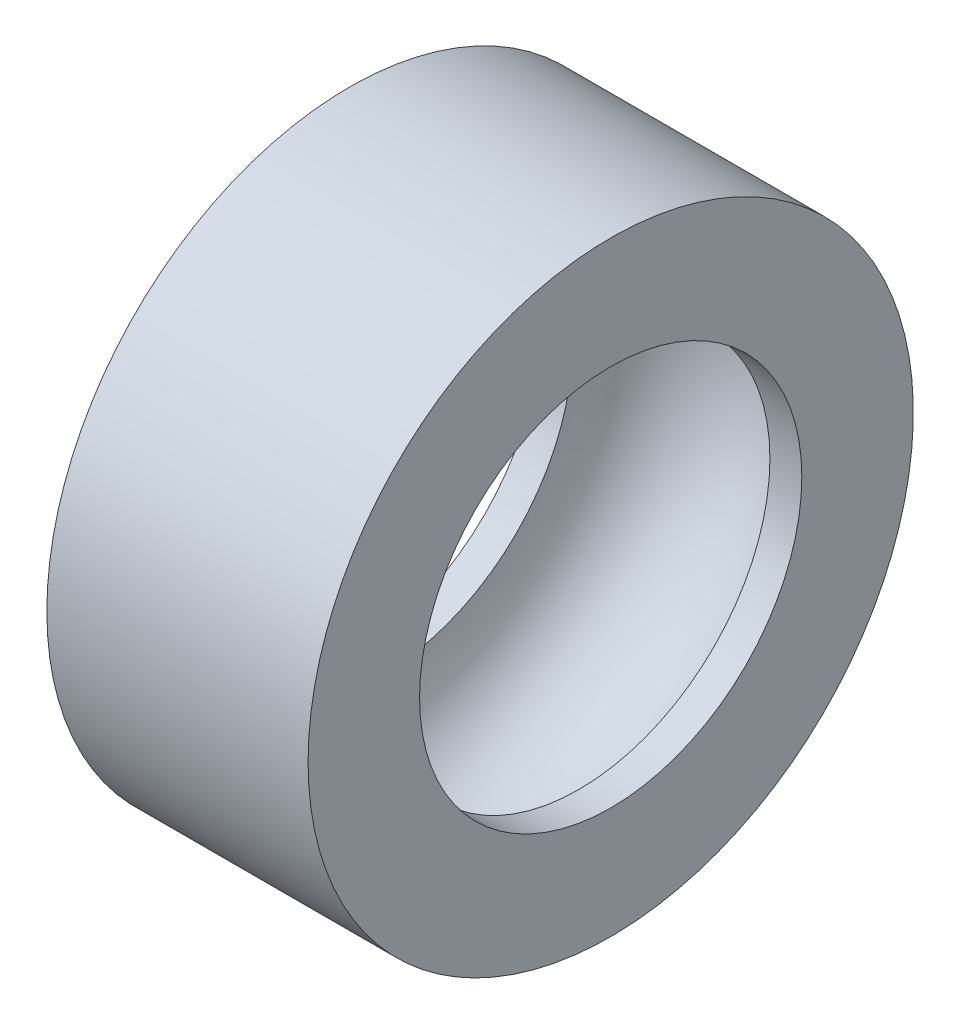
from build123d import *


with BuildPart() as part:
    # Sketch1 → Revolve1 (revolve)
    with BuildSketch(Plane.XY):
        with BuildLine():
            Line((4.1, 6), (3.098386677, 6))
            ThreePointArc((3.098386677, 6), (0, 9), (-3.098386677, 6))
            Line((-3.098386677, 6), (-4.1, 6))
            Line((-4.1, 6), (-4.1, 9.5))
            Line((-4.1, 9.5), (4.1, 9.5))
            Line((4.1, 9.5), (4.1, 6))
        make_face()
    revolve(axis=Axis((-10.900544186, 0, 0), (1, 0, 0)))


solid = part.part
